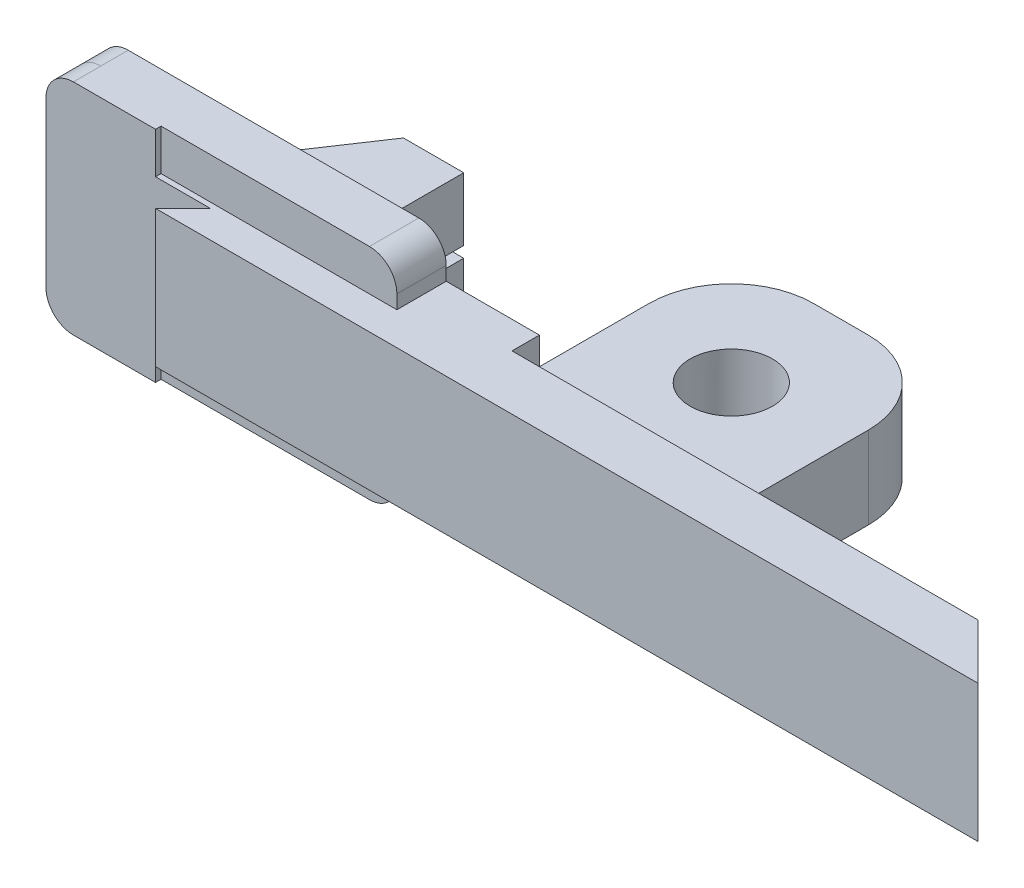
from build123d import *

# Parameters (mm, degrees)
SZKIC1_W                    = 150
SZKIC1_H                    = 25
DODANIE_WYCI_GNI_CIE1_DEPTH = 5
WYTNIJ_WYCI_GNI_CIE1_DEPTH  = 26
SZKIC3_W                    = 90
SZKIC3_H                    = 40
DODANIE_WYCI_GNI_CIE2_DEPTH = 5
ZAOKR_GLENIE1_R             = 5
SZKIC4_W                    = 75
SZKIC4_H                    = 25
DODANIE_WYCI_GNI_CIE3_DEPTH = 5
DODANIE_WYCI_GNI_CIE4_DEPTH = 25
SZKIC6_W                    = 40
SZKIC6_H                    = 25
DODANIE_WYCI_GNI_CIE5_DEPTH = 40
ZAOKR_GLENIE2_R             = 15
SZKIC7_R                    = 7.5
WYTNIJ_WYCI_GNI_CIE2_DEPTH  = 40
SZKIC10_W                   = 27
SZKIC10_H                   = 7.5
WYTNIJ_WYCI_GNI_CIE5_DEPTH  = 10
DODANIE_WYCI_GNI_CIE7_DEPTH = 5
ZAOKR_GLENIE5_R             = 5
ZAOKR_GLENIE6_R             = 5
DODANIE_WYCI_GNI_CIE8_DEPTH = 12.5
SZKIC21_W                   = 15.7980857
SZKIC21_H                   = 2
WYTNIJ_WYCI_GNI_CIE8_DEPTH  = 25
WYTNIJ_WYCI_GNI_CIE9_DEPTH  = 7.5
SZKIC23_W                   = 40
SZKIC23_H                   = 5
WYTNIJ_WYCI_GNI_CIE10_DEPTH = 40
SZKIC24_W                   = 38
SZKIC24_H                   = 7.5
WYTNIJ_WYCI_GNI_CIE11_DEPTH = 1
SZKIC25_W                   = 5.016656034
SZKIC25_H                   = 7.5
WYTNIJ_WYCI_GNI_CIE12_DEPTH = 1


with BuildPart() as part:
    # Szkic1 → Dodanie-wyciągnięcie1 (new body)
    with BuildSketch(Plane.XY):
        Rectangle(SZKIC1_W, SZKIC1_H)
    extrude(amount=DODANIE_WYCI_GNI_CIE1_DEPTH)

    # Szkic2 → Wytnij-wyciągnięcie1 (cut, through all)
    with BuildSketch(Plane(origin=(0, 12.5, 0), x_dir=(1, 0, 0), z_dir=(0, 1, 0))):
        Polygon((75, -5), (70, 0), (75, 0), align=None)
        Polygon((-70, 0), (-75, 0), (-75, -5), align=None)
    extrude(amount=-WYTNIJ_WYCI_GNI_CIE1_DEPTH, mode=Mode.SUBTRACT)

    # Szkic3 → Dodanie-wyciągnięcie2 (add)
    with BuildSketch(Plane(origin=(0, 0, 0), x_dir=(-1, 0, 0), z_dir=(0, 0, -1))):
        with Locations((55, 0)):
            Rectangle(SZKIC3_W, SZKIC3_H)
    extrude(amount=DODANIE_WYCI_GNI_CIE2_DEPTH)

    # Zaokrąglenie1
    zaokr_glenie1_edges = [part.edges().sort_by_distance(p)[0] for p in [
        (-100, -20, -2.5),
        (-100, 20, -2.5),
        (-10, 20, -2.5),
        (-10, -20, -2.5),
    ]]
    fillet(zaokr_glenie1_edges, radius=ZAOKR_GLENIE1_R)

    # Szkic4 → Dodanie-wyciągnięcie3 (add)
    with BuildSketch(Plane(origin=(0, 0, 0), x_dir=(-1, 0, 0), z_dir=(0, 0, -1))):
        with Locations((-27.5, 0)):
            Rectangle(SZKIC4_W, SZKIC4_H)
    extrude(amount=DODANIE_WYCI_GNI_CIE3_DEPTH)

    # Szkic5 → Dodanie-wyciągnięcie4 (add)
    with BuildSketch(Plane.XZ.offset(12.5)):
        Polygon((65, 0), (70, 0), (65, -5), align=None)
    extrude(amount=-DODANIE_WYCI_GNI_CIE4_DEPTH)

    # Szkic6 → Dodanie-wyciągnięcie5 (add)
    with BuildSketch(Plane(origin=(0, 0, -5), x_dir=(-1, 0, 0), z_dir=(0, 0, -1))):
        Rectangle(SZKIC6_W, SZKIC6_H)
    extrude(amount=DODANIE_WYCI_GNI_CIE5_DEPTH)

    # Zaokrąglenie2
    zaokr_glenie2_edges = [part.edges().sort_by_distance(p)[0] for p in [
        (20, 0, -45),
        (-20, 0, -45),
    ]]
    fillet(zaokr_glenie2_edges, radius=ZAOKR_GLENIE2_R)

    # Szkic7 → Wytnij-wyciągnięcie2 (cut)
    with BuildSketch(Plane(origin=(0, 12.5, 0), x_dir=(1, 0, 0), z_dir=(0, 1, 0))):
        with Locations((0, 25)):
            Circle(SZKIC7_R)
    extrude(amount=-WYTNIJ_WYCI_GNI_CIE2_DEPTH, mode=Mode.SUBTRACT)

    # Szkic10 → Wytnij-wyciągnięcie5 (cut)
    with BuildSketch(Plane.XY):
        with Locations((-23.5, 16.25)):
            Rectangle(SZKIC10_W, SZKIC10_H)
        with Locations((-23.5, -16.25)):
            Rectangle(SZKIC10_W, SZKIC10_H)
    extrude(amount=-WYTNIJ_WYCI_GNI_CIE5_DEPTH, mode=Mode.SUBTRACT)

    # Szkic11 → Dodanie-wyciągnięcie7 (add)
    with BuildSketch(Plane(origin=(0, 0, -5), x_dir=(-1, 0, 0), z_dir=(0, 0, -1))):
        Polygon((37, 20), (100, 20), (100, -20), (37, -20), (37, -12.5), (20, -12.5), (20, 12.5), (37, 12.5), align=None)
    extrude(amount=DODANIE_WYCI_GNI_CIE7_DEPTH)

    # Zaokrąglenie5
    zaokr_glenie5_edges = [part.edges().sort_by_distance(p)[0] for p in [
        (-100, 20, -7.5),
        (-100, -20, -7.5),
    ]]
    fillet(zaokr_glenie5_edges, radius=ZAOKR_GLENIE5_R)

    # Zaokrąglenie6
    zaokr_glenie6_edges = [part.edges().sort_by_distance(p)[0] for p in [
        (-37, 20, -5),
        (-37, -20, -5),
    ]]
    fillet(zaokr_glenie6_edges, radius=ZAOKR_GLENIE6_R)

    # Szkic19 → Dodanie-wyciągnięcie8 (add, symmetric)
    with BuildSketch(Plane(origin=(0, 0, 0), x_dir=(1, 0, 0), z_dir=(0, 1, 0))):
        Polygon((-76.073569431, 10), (-63.538877319, 28.741535124), (-52.546253684, 28.741535124), (-52.546253684, 10), align=None)
    extrude(amount=DODANIE_WYCI_GNI_CIE8_DEPTH, both=True)

    # Szkic21 → Wytnij-wyciągnięcie8 (cut)
    with BuildSketch(Plane(origin=(-52.546253684, 0, 0), x_dir=(0, 0, -1), z_dir=(1, 0, 0))):
        with Locations((20.842492274, 0)):
            Rectangle(SZKIC21_W, SZKIC21_H)
    extrude(amount=-WYTNIJ_WYCI_GNI_CIE8_DEPTH, mode=Mode.SUBTRACT)

    # Szkic22 → Wytnij-wyciągnięcie9 (cut, symmetric)
    with BuildSketch(Plane(origin=(0, 0, 0), x_dir=(1, 0, 0), z_dir=(0, 1, 0))):
        with BuildLine():
            Line((-52.546253684, 12), (-53.546253684, 12))
            ThreePointArc((-53.546253684, 12), (-57.546253684, 16), (-53.546253684, 20))
            Line((-53.546253684, 20), (-52.546253684, 20))
            Line((-52.546253684, 20), (-52.546253684, 12))
        make_face()
    extrude(amount=WYTNIJ_WYCI_GNI_CIE9_DEPTH, both=True, mode=Mode.SUBTRACT)

    # Szkic23 → Wytnij-wyciągnięcie10 (cut)
    with BuildSketch(Plane(origin=(0, 0, -45), x_dir=(-1, 0, 0), z_dir=(0, 0, -1))):
        with Locations((0, 10)):
            Rectangle(SZKIC23_W, SZKIC23_H)
        with Locations((0, -10)):
            Rectangle(SZKIC23_W, SZKIC23_H)
    extrude(amount=-WYTNIJ_WYCI_GNI_CIE10_DEPTH, mode=Mode.SUBTRACT)

    # Szkic24 → Wytnij-wyciągnięcie11 (cut)
    with BuildSketch(Plane.XY):
        with Locations((-56, 16.25)):
            Rectangle(SZKIC24_W, SZKIC24_H)
        with Locations((-56, -16.25)):
            Rectangle(SZKIC24_W, SZKIC24_H)
    extrude(amount=-WYTNIJ_WYCI_GNI_CIE11_DEPTH, mode=Mode.SUBTRACT)

    # Szkic25 → Wytnij-wyciągnięcie12 (cut)
    with BuildSketch(Plane.XY):
        with Locations((-77.508328017, 16.25)):
            Rectangle(SZKIC25_W, SZKIC25_H)
        with Locations((-77.508328017, -16.25)):
            Rectangle(SZKIC25_W, SZKIC25_H)
    extrude(amount=-WYTNIJ_WYCI_GNI_CIE12_DEPTH, mode=Mode.SUBTRACT)


solid = part.part
